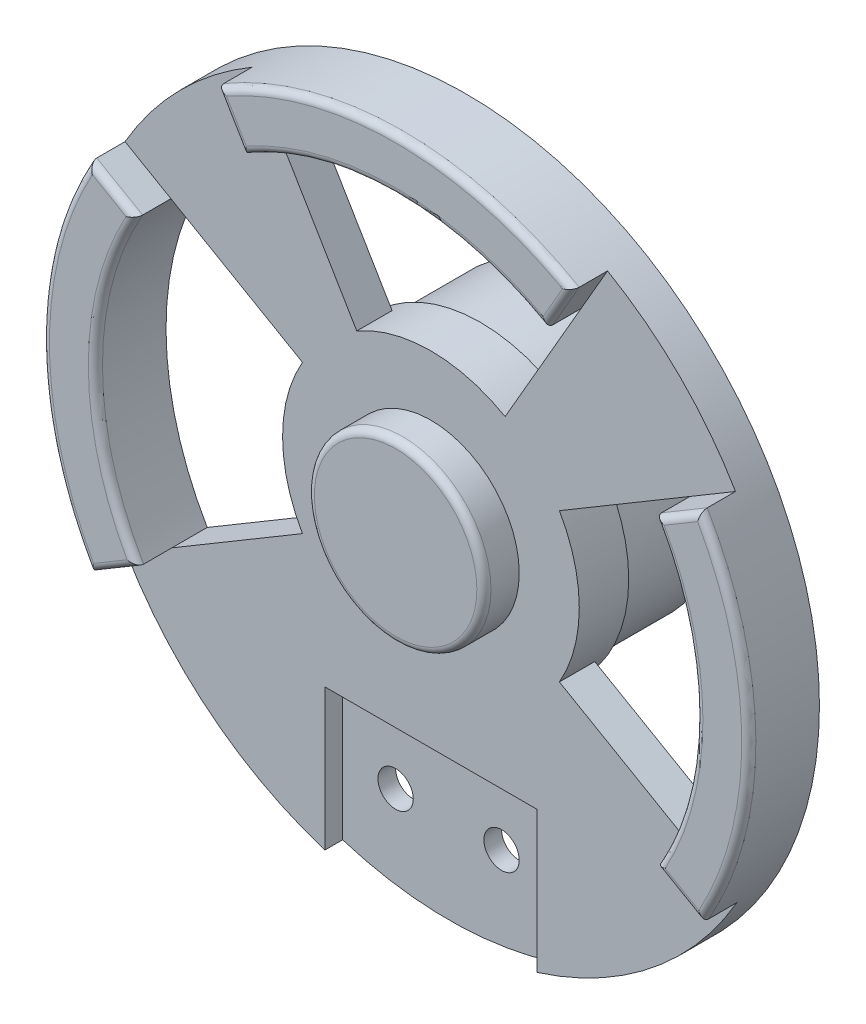
from build123d import *

# Parameters (mm, degrees)
SKETCH1_R           = 19.875
BOSS_EXTRUDE1_DEPTH = 15
SKETCH2_R           = 21
BOSS_EXTRUDE2_DEPTH = 2
SKETCH3_R           = 50
BOSS_EXTRUDE3_DEPTH = 5
CUT_EXTRUDE2_DEPTH  = 5
CUT_EXTRUDE3_DEPTH  = 2.5
SKETCH8_R           = 2.5
CUT_EXTRUDE4_DEPTH  = 20.5
BOSS_EXTRUDE4_DEPTH = 5
FILLET1_R           = 1
CHAMFER1_SIZE       = 2
SKETCH10_R          = 12.5
BOSS_EXTRUDE5_DEPTH = 5
FILLET2_R           = 1


with BuildPart() as part:
    # Sketch1 → Boss-Extrude1 (new body)
    with BuildSketch(Plane.XY):
        Circle(SKETCH1_R)
    extrude(amount=BOSS_EXTRUDE1_DEPTH)

    # Sketch2 → Boss-Extrude2 (add)
    with BuildSketch(Plane.XY.offset(15)):
        Circle(SKETCH2_R)
    extrude(amount=BOSS_EXTRUDE2_DEPTH)

    # Sketch3 → Boss-Extrude3 (add)
    with BuildSketch(Plane.XY.offset(17)):
        Circle(SKETCH3_R)
    extrude(amount=BOSS_EXTRUDE3_DEPTH)

    # Sketch4 → Cut-Extrude2 (cut)
    with BuildSketch(Plane(origin=(0, 0, 17), x_dir=(-1, 0, 0), z_dir=(0, 0, -1))):
        with BuildLine():
            ThreePointArc((-18.186533479, -10.5), (-21, 0), (-18.186533479, 10.5))
            Line((-18.186533479, 10.5), (-36.669606346, 21.484644991))
            ThreePointArc((-36.669606346, 21.484644991), (-42.499783284, 0.135723282), (-36.806079661, -21.25))
            Line((-36.806079661, -21.25), (-18.186533479, -10.5))
        make_face()
        with BuildLine():
            Line((-21.25, 36.806079661), (-10.5, 18.186533479))
            ThreePointArc((-10.5, 18.186533479), (0, 21), (10.5, 18.186533479))
            Line((10.5, 18.186533479), (21.484644991, 36.669606346))
            ThreePointArc((21.484644991, 36.669606346), (0.135723282, 42.499783284), (-21.25, 36.806079661))
        make_face()
        with BuildLine():
            Line((36.806079661, 21.25), (18.186533479, 10.5))
            ThreePointArc((18.186533479, 10.5), (20.284442352, 5.435199947), (21, 0))
            ThreePointArc((21, 0), (20.284442352, -5.435199947), (18.186533479, -10.5))
            Line((18.186533479, -10.5), (36.669606346, -21.484644991))
            ThreePointArc((36.669606346, -21.484644991), (42.499783284, -0.135723282), (36.806079661, 21.25))
        make_face()
    extrude(amount=-CUT_EXTRUDE2_DEPTH, mode=Mode.SUBTRACT)

    # Sketch5 → Cut-Extrude3 (cut)
    with BuildSketch(Plane.XY.offset(22)):
        with BuildLine():
            Line((-15, -47.696960071), (-15, -27.696960071))
            Line((-15, -27.696960071), (15, -27.696960071))
            Line((15, -27.696960071), (15, -47.696960071))
            ThreePointArc((15, -47.696960071), (0, -50), (-15, -47.696960071))
        make_face()
    extrude(amount=-CUT_EXTRUDE3_DEPTH, mode=Mode.SUBTRACT)

    # Sketch8 → Cut-Extrude4 (cut, through all)
    with BuildSketch(Plane.XY.offset(19.5)):
        with Locations((-7.5, -37.696960071)):
            Circle(SKETCH8_R)
        with Locations((7.5, -37.696960071)):
            Circle(SKETCH8_R)
    extrude(amount=-CUT_EXTRUDE4_DEPTH, mode=Mode.SUBTRACT)

    # Sketch9 → Boss-Extrude4 (add)
    with BuildSketch(Plane.XY.offset(22)):
        with BuildLine():
            Line((-36.806079661, 21.25), (-43.301270189, 25))
            ThreePointArc((-43.301270189, 25), (-49.999664861, -0.183067825), (-43.117042638, -25.316410373))
            Line((-43.117042638, -25.316410373), (-36.669606346, -21.484644991))
            ThreePointArc((-36.669606346, -21.484644991), (-42.499783284, -0.135723282), (-36.806079661, 21.25))
        make_face()
        with BuildLine():
            Line((-21.484644991, 36.669606346), (-25.316410373, 43.117042638))
            ThreePointArc((-25.316410373, 43.117042638), (-0.183067825, 49.999664861), (25, 43.301270189))
            Line((25, 43.301270189), (21.25, 36.806079661))
            ThreePointArc((21.25, 36.806079661), (-0.135723282, 42.499783284), (-21.484644991, 36.669606346))
        make_face()
        with BuildLine():
            Line((36.669606346, 21.484644991), (43.117042638, 25.316410373))
            ThreePointArc((43.117042638, 25.316410373), (49.999664861, 0.183067825), (43.301270189, -25))
            Line((43.301270189, -25), (36.806079661, -21.25))
            ThreePointArc((36.806079661, -21.25), (42.499783284, 0.135723282), (36.669606346, 21.484644991))
        make_face()
    extrude(amount=BOSS_EXTRUDE4_DEPTH)

    # Fillet1
    fillet1_edges = [part.edges().sort_by_distance(p)[0] for p in [
        (-0.183067825, 49.999664861, 27),
        (-23.400527682, 39.893324492, 27),
        (42.499783284, 0.135723282, 27),
        (40.053674925, -23.125, 27),
        (49.999664861, 0.183067825, 27),
        (39.893324492, 23.400527682, 27),
        (-42.499783284, -0.135723282, 27),
        (-40.053674925, 23.125, 27),
        (-49.999664861, -0.183067825, 27),
        (-39.893324492, -23.400527682, 27),
        (-0.135723282, 42.499783284, 27),
        (23.125, 40.053674925, 27),
    ]]
    fillet(fillet1_edges, radius=FILLET1_R)

    # Chamfer1
    chamfer1_edges = [part.edges().sort_by_distance(p)[0] for p in [
        (-19.875, 0, 0),
    ]]
    chamfer(chamfer1_edges, length=CHAMFER1_SIZE)

    # Sketch10 → Boss-Extrude5 (add)
    with BuildSketch(Plane.XY.offset(22)):
        Circle(SKETCH10_R)
    extrude(amount=BOSS_EXTRUDE5_DEPTH)

    # Fillet2
    fillet2_edges = [part.edges().sort_by_distance(p)[0] for p in [
        (-12.5, 0, 27),
    ]]
    fillet(fillet2_edges, radius=FILLET2_R)


solid = part.part
